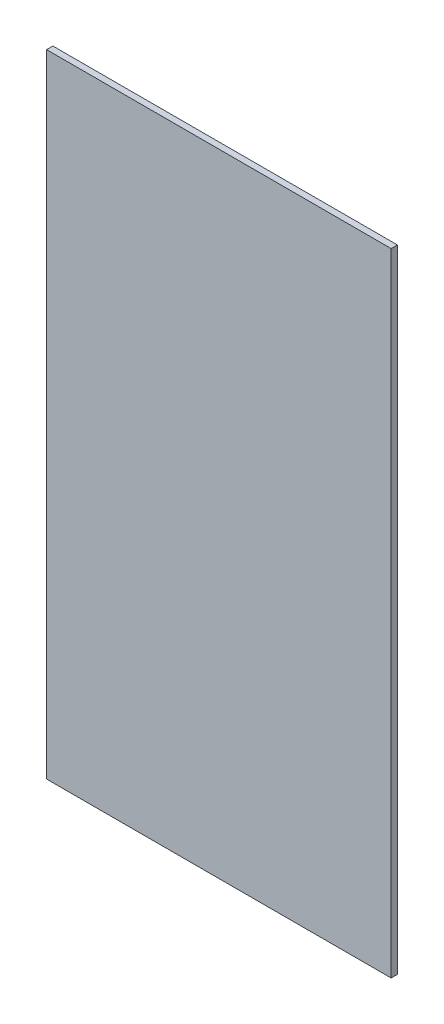
from build123d import *

# Parameters (mm, degrees)
SKETCH1_W           = 609.6
SKETCH1_H           = 1117.6
BOSS_EXTRUDE1_DEPTH = 11.1125


with BuildPart() as part:
    # Sketch1 → Boss-Extrude1 (new body)
    with BuildSketch(Plane.XY):
        with Locations((304.8, 558.8)):
            Rectangle(SKETCH1_W, SKETCH1_H)
    extrude(amount=BOSS_EXTRUDE1_DEPTH)


solid = part.part
